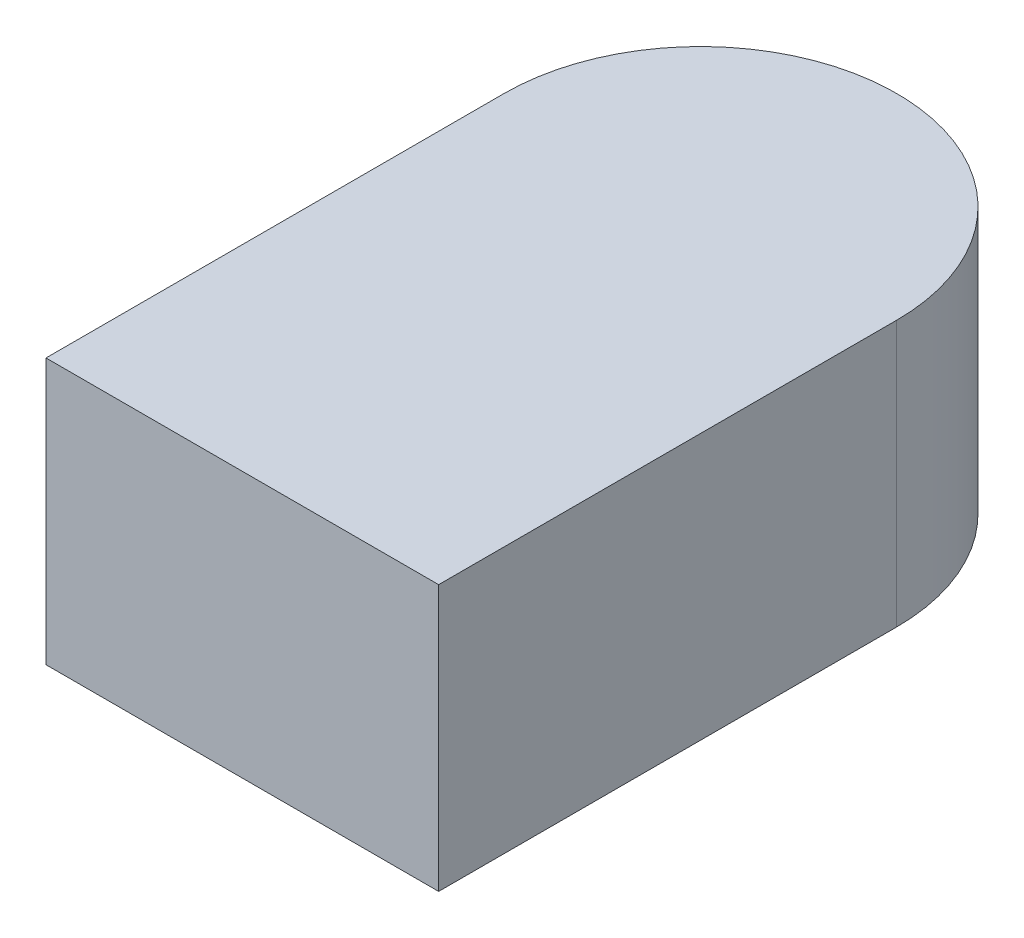
from build123d import *

# Parameters (mm, degrees)
BOSS_EXTRUDE1_DEPTH = 0.203


with BuildPart() as part:
    # Sketch1 → Boss-Extrude1 (new body)
    with BuildSketch(Plane(origin=(0, 0, 0), x_dir=(1, 0, 0), z_dir=(0, 1, 0))):
        with BuildLine():
            Line((-0.15, 0.175), (-0.15, -0.175))
            Line((-0.15, -0.175), (0.15, -0.175))
            Line((0.15, -0.175), (0.15, 0.175))
            ThreePointArc((0.15, 0.175), (0, 0.325), (-0.15, 0.175))
        make_face()
    extrude(amount=BOSS_EXTRUDE1_DEPTH)


solid = part.part
